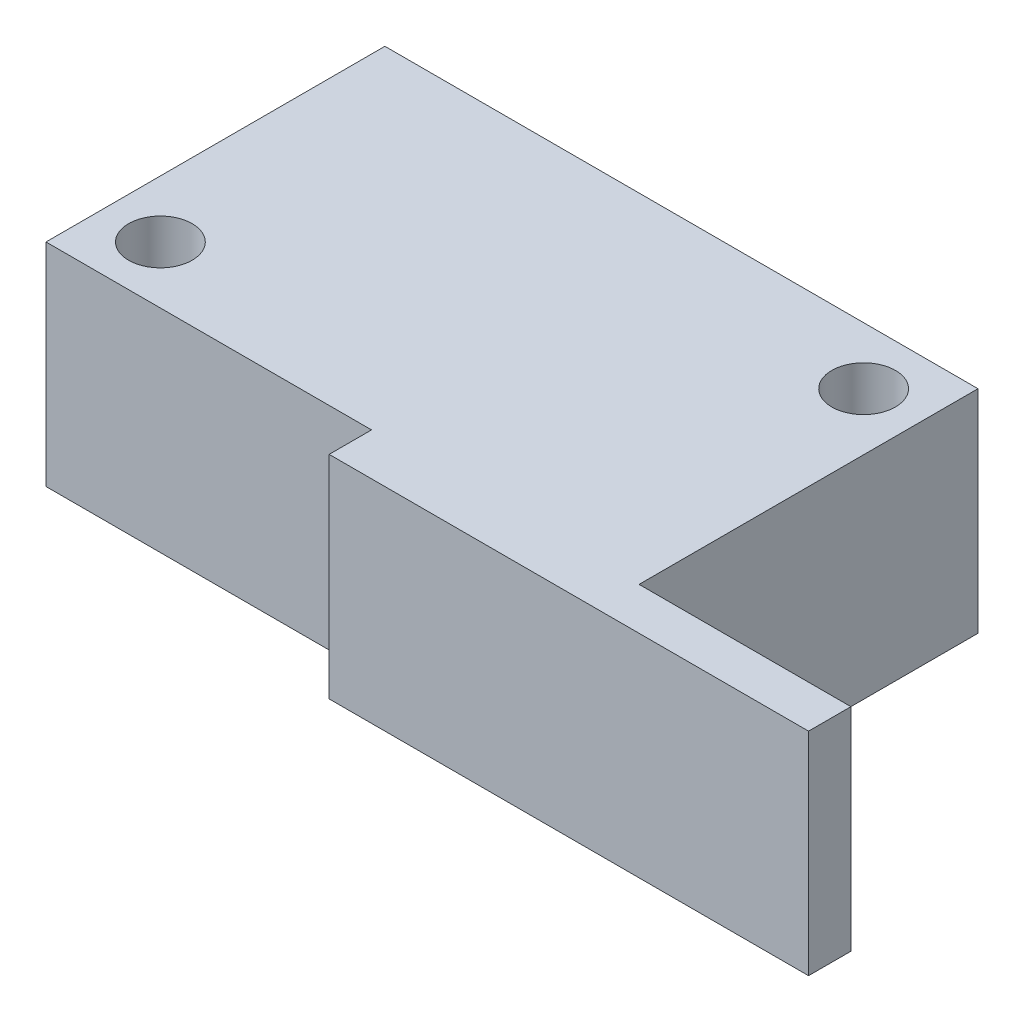
from build123d import *

# Parameters (mm, degrees)
SKETCH1_W           = 28
SKETCH1_H           = 16
BOSS_EXTRUDE1_DEPTH = 10
CUT_EXTRUDE1_REACH  = 12
SKETCH2_R           = 1.5
SKETCH3_W           = 22.631801359
SKETCH3_H           = 10
BOSS_EXTRUDE2_DEPTH = 2


with BuildPart() as part:
    # Sketch1 → Boss-Extrude1 (new body)
    with BuildSketch(Plane(origin=(0, 0, 0), x_dir=(1, 0, 0), z_dir=(0, 1, 0))):
        Rectangle(SKETCH1_W, SKETCH1_H)
    extrude(amount=BOSS_EXTRUDE1_DEPTH)

    # Sketch2 → Cut-Extrude1 (cut, up to next)
    with BuildSketch(Plane(origin=(0, 10, 0), x_dir=(1, 0, 0), z_dir=(0, 1, 0)), mode=Mode.PRIVATE) as cut_extrude1_sk1:
        with Locations((-11.3, -5.3)):
            Circle(SKETCH2_R)
    cut_extrude1_tool1 = extrude(cut_extrude1_sk1.sketch, amount=-CUT_EXTRUDE1_REACH, mode=Mode.PRIVATE) & part.part
    add(cut_extrude1_tool1.solids().sort_by_distance((-11.3, 10, 5.3))[0], mode=Mode.SUBTRACT)
    # Sketch2 → Cut-Extrude1 (cut, up to next)
    with BuildSketch(Plane(origin=(0, 10, 0), x_dir=(1, 0, 0), z_dir=(0, 1, 0)), mode=Mode.PRIVATE) as cut_extrude1_sk2:
        with Locations((11.3, 5.3)):
            Circle(SKETCH2_R)
    cut_extrude1_tool2 = extrude(cut_extrude1_sk2.sketch, amount=-CUT_EXTRUDE1_REACH, mode=Mode.PRIVATE) & part.part
    add(cut_extrude1_tool2.solids().sort_by_distance((11.3, 10, -5.3))[0], mode=Mode.SUBTRACT)

    # Sketch3 → Boss-Extrude2 (add)
    with BuildSketch(Plane.XY.offset(8)):
        with Locations((12.68409932, 5)):
            Rectangle(SKETCH3_W, SKETCH3_H)
    extrude(amount=BOSS_EXTRUDE2_DEPTH)


solid = part.part
